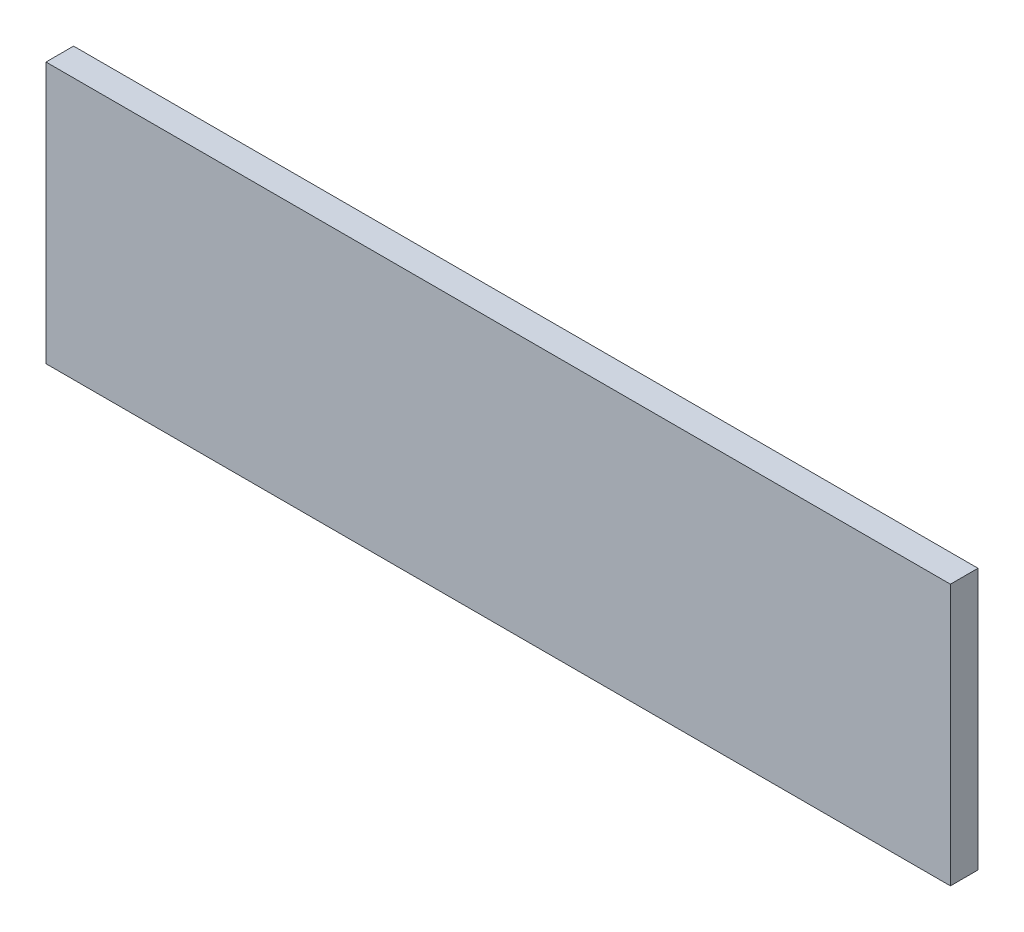
from build123d import *

# Parameters (mm, degrees)
SKIZZE1_W                       = 623
SKIZZE1_H                       = 180
AUFSATZ_LINEAR_AUSTRAGEN1_DEPTH = 19


with BuildPart() as part:
    # Skizze1 → Aufsatz-Linear austragen1 (new body)
    with BuildSketch(Plane.XY):
        Rectangle(SKIZZE1_W, SKIZZE1_H)
    extrude(amount=AUFSATZ_LINEAR_AUSTRAGEN1_DEPTH)


solid = part.part
